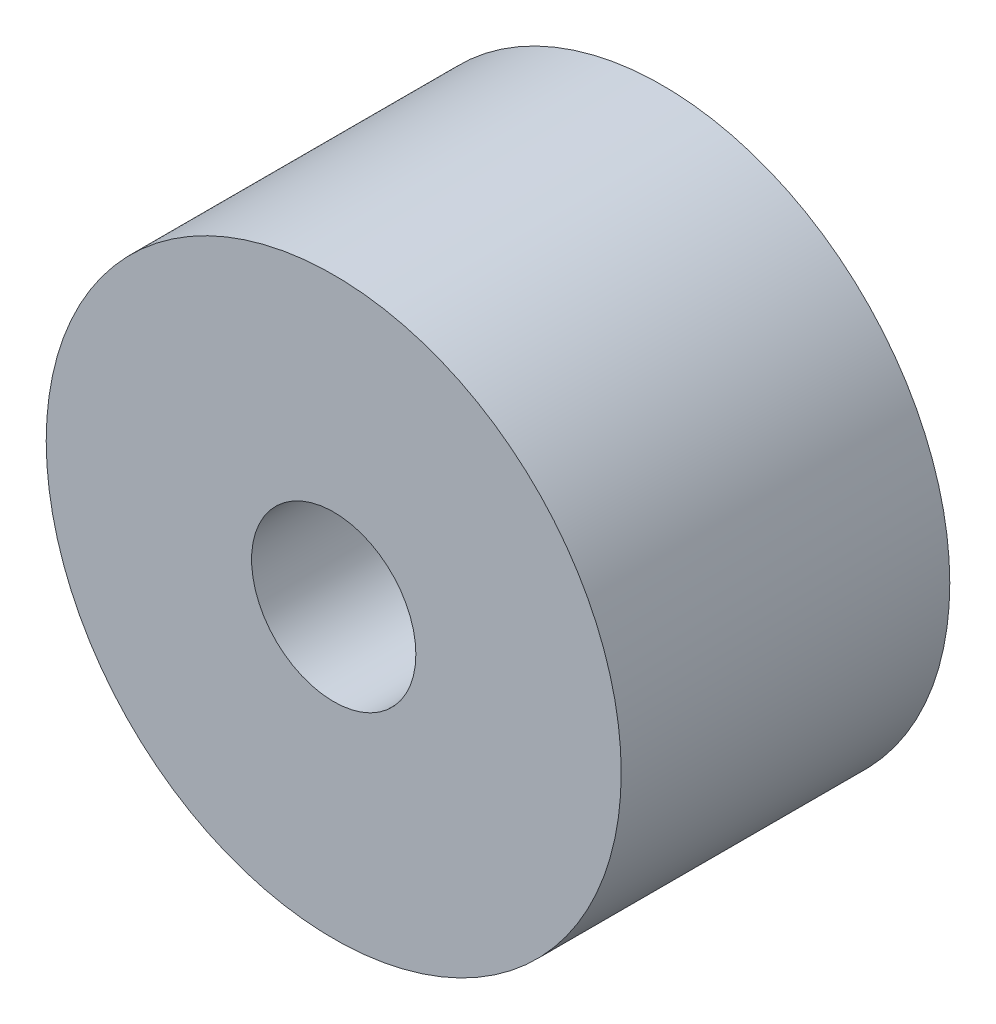
from build123d import *

# Parameters (mm, degrees)
CROQUIS1_R              = 17.5
CROQUIS1_R_2            = 5
SALIENTE_EXTRUIR1_DEPTH = 10


with BuildPart() as part:
    # Croquis1 → Saliente-Extruir1 (new body, symmetric)
    with BuildSketch(Plane.XY):
        Circle(CROQUIS1_R)
        Circle(CROQUIS1_R_2, mode=Mode.SUBTRACT)
    extrude(amount=SALIENTE_EXTRUIR1_DEPTH, both=True)


solid = part.part
